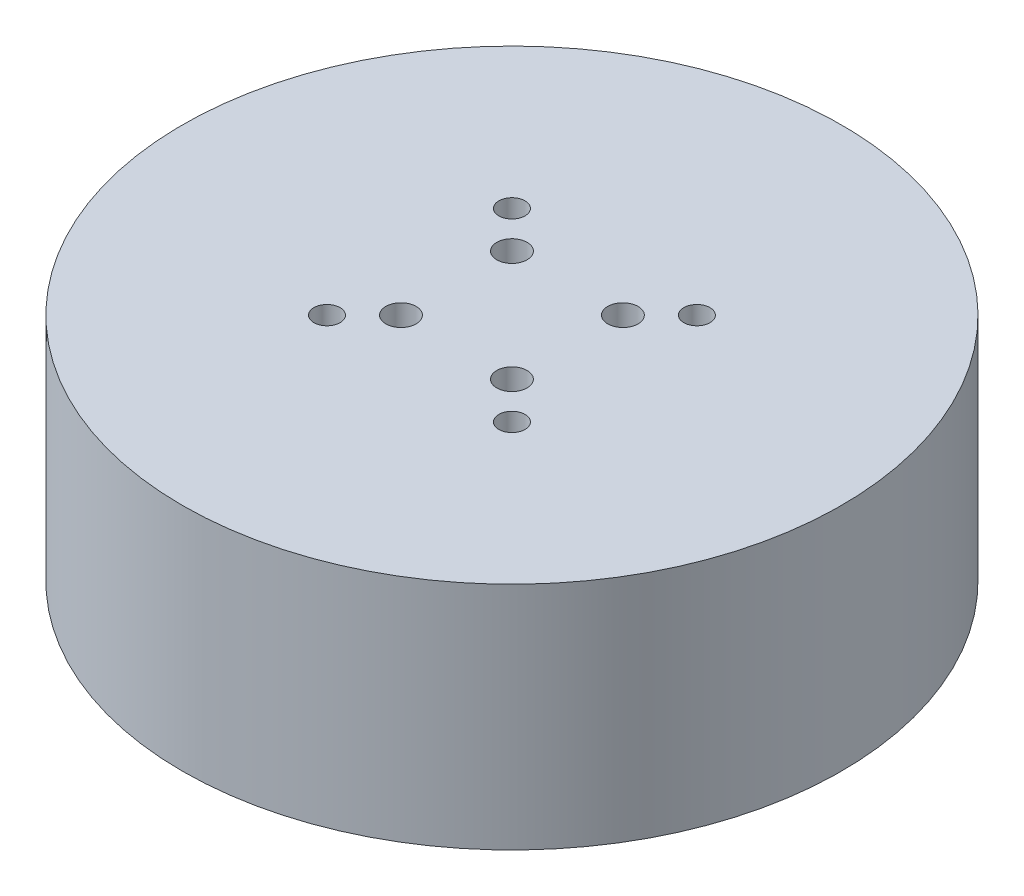
from build123d import *

# Parameters (mm, degrees)
SKETCH1_R                          = 31.5
BOSS_EXTRUDE1_DEPTH                = 22
TAP_DRILL_FOR_M3X0_5_TAP1_D        = 2.5
TAP_DRILL_FOR_M3X0_5_TAP1_DEPTH    = 4.76
TAP_DRILL_FOR_M3X0_5_TAP1_TIP      = 0.751075774
TAP_DRILL_FOR_M2_5X0_45_TAP1_D     = 2.05
TAP_DRILL_FOR_M2_5X0_45_TAP1_DEPTH = 3.5
TAP_DRILL_FOR_M2_5X0_45_TAP1_TIP   = 0.615882135
M2_5_CLEARANCE_HOLE1_D             = 2.9


with BuildPart() as part:
    # Sketch1 → Boss-Extrude1 (new body)
    with BuildSketch(Plane(origin=(0, 0, 0), x_dir=(1, 0, 0), z_dir=(0, 1, 0))):
        Circle(SKETCH1_R)
    extrude(amount=BOSS_EXTRUDE1_DEPTH)

    # Tap Drill for M3x0.5 Tap1
    with Locations(Plane(origin=(0, 22, 0), x_dir=(1, 0, 0), z_dir=(0, 1, 0))):
        with Locations((8.838834765, 8.838834765), (8.838834765, -8.838834765), (-8.838834765, -8.838834765), (-8.838834765, 8.838834765)):
            Hole(TAP_DRILL_FOR_M3X0_5_TAP1_D / 2, depth=TAP_DRILL_FOR_M3X0_5_TAP1_DEPTH)
            with Locations((0, 0, -(TAP_DRILL_FOR_M3X0_5_TAP1_DEPTH + TAP_DRILL_FOR_M3X0_5_TAP1_TIP / 2))):  # 118° drill point
                Cone(0, TAP_DRILL_FOR_M3X0_5_TAP1_D / 2, TAP_DRILL_FOR_M3X0_5_TAP1_TIP, mode=Mode.SUBTRACT)

    # Tap Drill for M2.5x0.45 Tap1
    with Locations(Plane(origin=(0, 0, 0), x_dir=(-1, 0, 0), z_dir=(0, -1, 0))):
        with Locations((5.303300859, -5.303300859), (5.303300859, 5.303300859), (-5.303300859, -5.303300859), (-5.303300859, 5.303300859)):
            Hole(TAP_DRILL_FOR_M2_5X0_45_TAP1_D / 2, depth=TAP_DRILL_FOR_M2_5X0_45_TAP1_DEPTH)
            with Locations((0, 0, -(TAP_DRILL_FOR_M2_5X0_45_TAP1_DEPTH + TAP_DRILL_FOR_M2_5X0_45_TAP1_TIP / 2))):  # 118° drill point
                Cone(0, TAP_DRILL_FOR_M2_5X0_45_TAP1_D / 2, TAP_DRILL_FOR_M2_5X0_45_TAP1_TIP, mode=Mode.SUBTRACT)

    # M2.5 Clearance Hole1 (through all)
    with Locations(Plane(origin=(0, 22, 0), x_dir=(1, 0, 0), z_dir=(0, 1, 0))):
        with Locations((5.303300859, 5.303300859), (5.303300859, -5.303300859), (-5.303300859, -5.303300859), (-5.303300859, 5.303300859)):
            Hole(M2_5_CLEARANCE_HOLE1_D / 2)


solid = part.part
